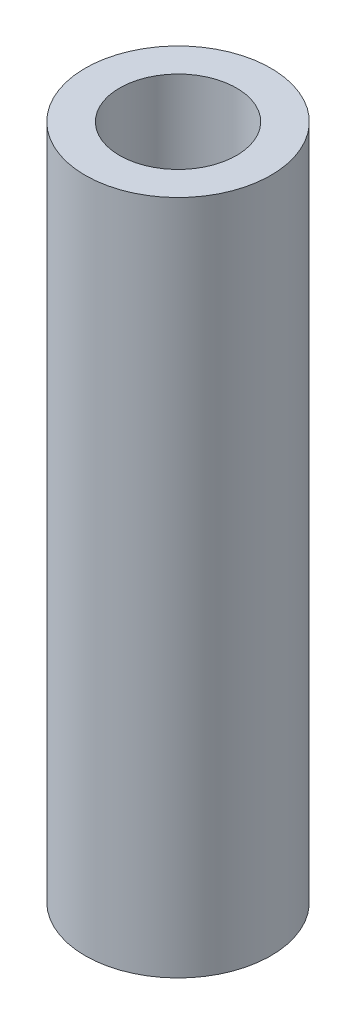
from build123d import *

# Parameters (mm, degrees)
SKETCH1_R           = 3.175
SKETCH1_R_2         = 2
BOSS_EXTRUDE1_DEPTH = 23.114


with BuildPart() as part:
    # Sketch1 → Boss-Extrude1 (new body)
    with BuildSketch(Plane(origin=(0, 0, 0), x_dir=(1, 0, 0), z_dir=(0, 1, 0))):
        Circle(SKETCH1_R)
        Circle(SKETCH1_R_2, mode=Mode.SUBTRACT)
    extrude(amount=-BOSS_EXTRUDE1_DEPTH)


solid = part.part
